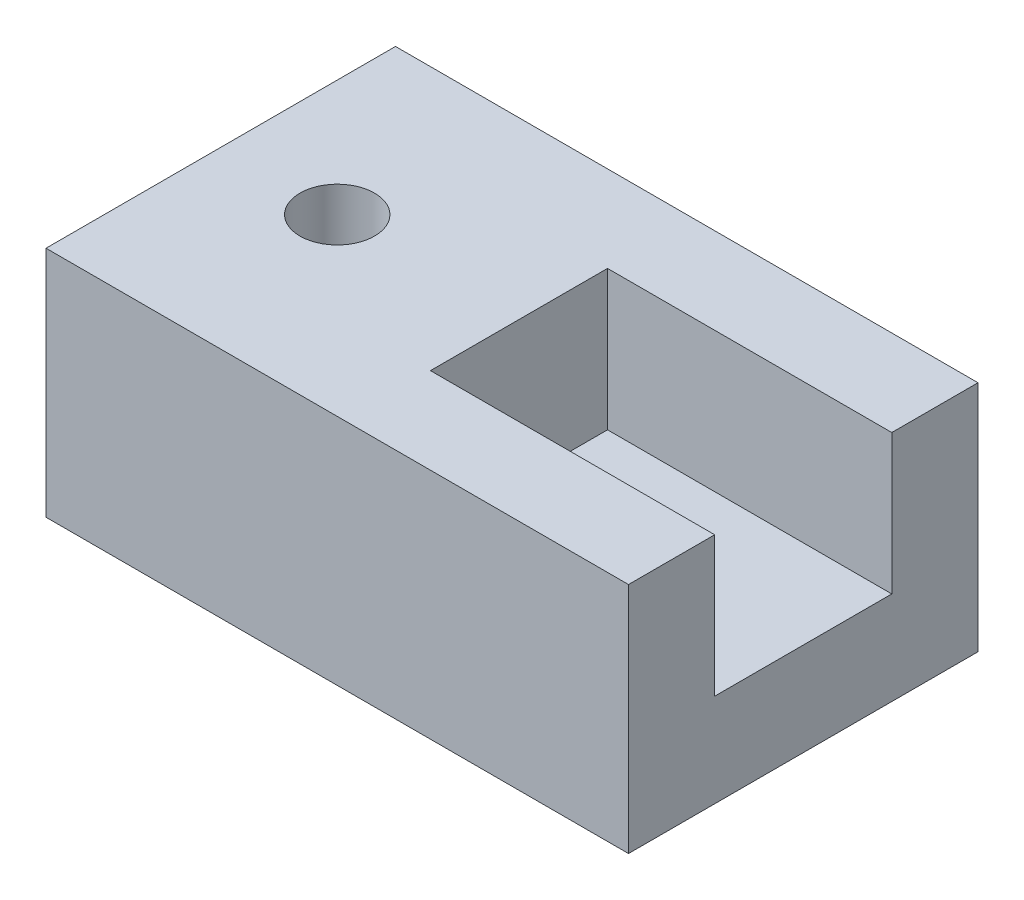
from build123d import *

# Parameters (mm, degrees)
SKETCH1_W           = 50
SKETCH1_H           = 30
BOSS_EXTRUDE1_DEPTH = 20
SKETCH3_W           = 15.2
SKETCH3_H           = 12
CUT_EXTRUDE1_DEPTH  = 51
SKETCH5_R           = 4.2
SKETCH5_R_2         = 3.2
CUT_EXTRUDE2_DEPTH  = 9
SKETCH6_W           = 25.6
SKETCH6_H           = 15.2
SKETCH6_R           = 3.2
BOSS_EXTRUDE2_DEPTH = 12


with BuildPart() as part:
    # Sketch1 → Boss-Extrude1 (new body)
    with BuildSketch(Plane(origin=(0, 0, 0), x_dir=(1, 0, 0), z_dir=(0, 1, 0))):
        Rectangle(SKETCH1_W, SKETCH1_H)
    extrude(amount=BOSS_EXTRUDE1_DEPTH)

    # Sketch3 → Cut-Extrude1 (cut, through all)
    with BuildSketch(Plane.ZY.offset(25)):
        with Locations((0, 14)):
            Rectangle(SKETCH3_W, SKETCH3_H)
    extrude(amount=-CUT_EXTRUDE1_DEPTH, mode=Mode.SUBTRACT)

    # Sketch5 → Cut-Extrude2 (cut, through all)
    with BuildSketch(Plane(origin=(0, 8, 0), x_dir=(1, 0, 0), z_dir=(0, 1, 0))):
        with Locations((11, 0)):
            Circle(SKETCH5_R)
        with Locations((-15, 0)):
            Circle(SKETCH5_R_2)
    extrude(amount=-CUT_EXTRUDE2_DEPTH, mode=Mode.SUBTRACT)

    # Sketch6 → Boss-Extrude2 (add)
    with BuildSketch(Plane(origin=(0, 8, 0), x_dir=(1, 0, 0), z_dir=(0, 1, 0))):
        with Locations((-12.2, 0)):
            Rectangle(SKETCH6_W, SKETCH6_H)
        with Locations((-15, 0)):
            Circle(SKETCH6_R, mode=Mode.SUBTRACT)
    extrude(amount=BOSS_EXTRUDE2_DEPTH)


solid = part.part
